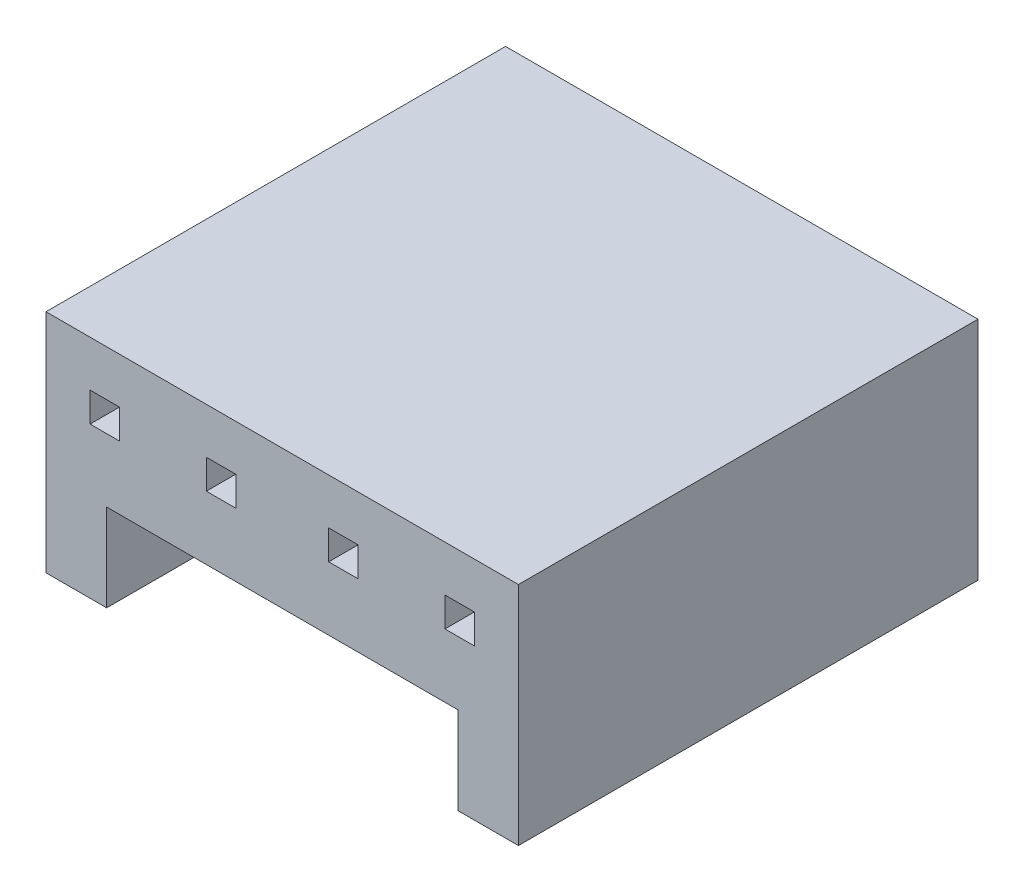
from build123d import *

# Parameters (mm, degrees)
SKETCH1_W           = 0.64
SKETCH1_H           = 0.64
BOSS_EXTRUDE1_DEPTH = 10


with BuildPart() as part:
    # Sketch1 → Boss-Extrude1 (new body)
    with BuildSketch(Plane.XY):
        Polygon((0, 4.92), (10.28, 4.92), (10.28, 0), (8.96, 0), (8.96, 1.9), (1.32, 1.9), (1.32, 0), (0, 0), align=None)
        with Locations((6.471040223, 3.602802159)):
            Rectangle(SKETCH1_W, SKETCH1_H, mode=Mode.SUBTRACT)
        with Locations((1.278959777, 3.602802159)):
            Rectangle(SKETCH1_W, SKETCH1_H, mode=Mode.SUBTRACT)
        with Locations((3.808959777, 3.602802159)):
            Rectangle(SKETCH1_W, SKETCH1_H, mode=Mode.SUBTRACT)
        with Locations((9.001040223, 3.602802159)):
            Rectangle(SKETCH1_W, SKETCH1_H, mode=Mode.SUBTRACT)
    extrude(amount=-BOSS_EXTRUDE1_DEPTH)


solid = part.part
